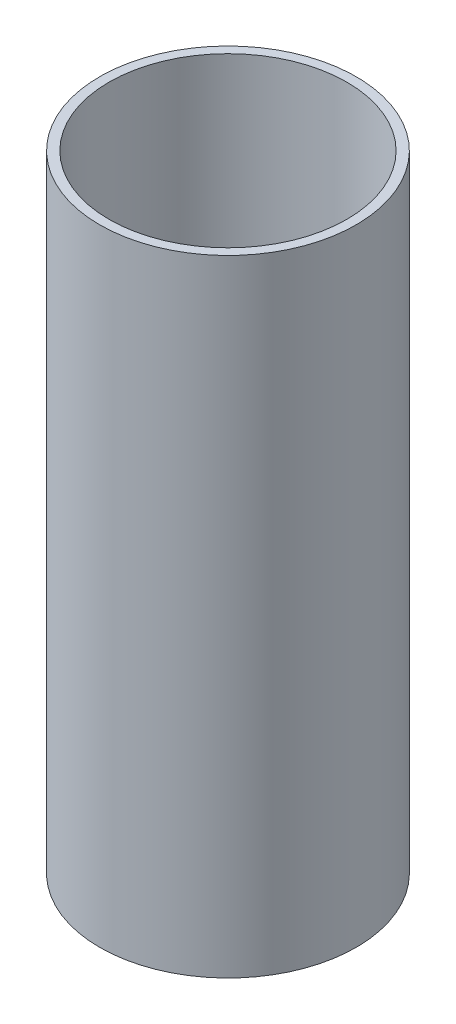
from build123d import *

# Parameters (mm, degrees)
SKETCH1_R           = 20.5
SKETCH1_R_2         = 19
BOSS_EXTRUDE1_DEPTH = 100


with BuildPart() as part:
    # Sketch1 → Boss-Extrude1 (new body)
    with BuildSketch(Plane(origin=(0, 0, 0), x_dir=(1, 0, 0), z_dir=(0, 1, 0))):
        Circle(SKETCH1_R)
        Circle(SKETCH1_R_2, mode=Mode.SUBTRACT)
    extrude(amount=BOSS_EXTRUDE1_DEPTH)


solid = part.part
